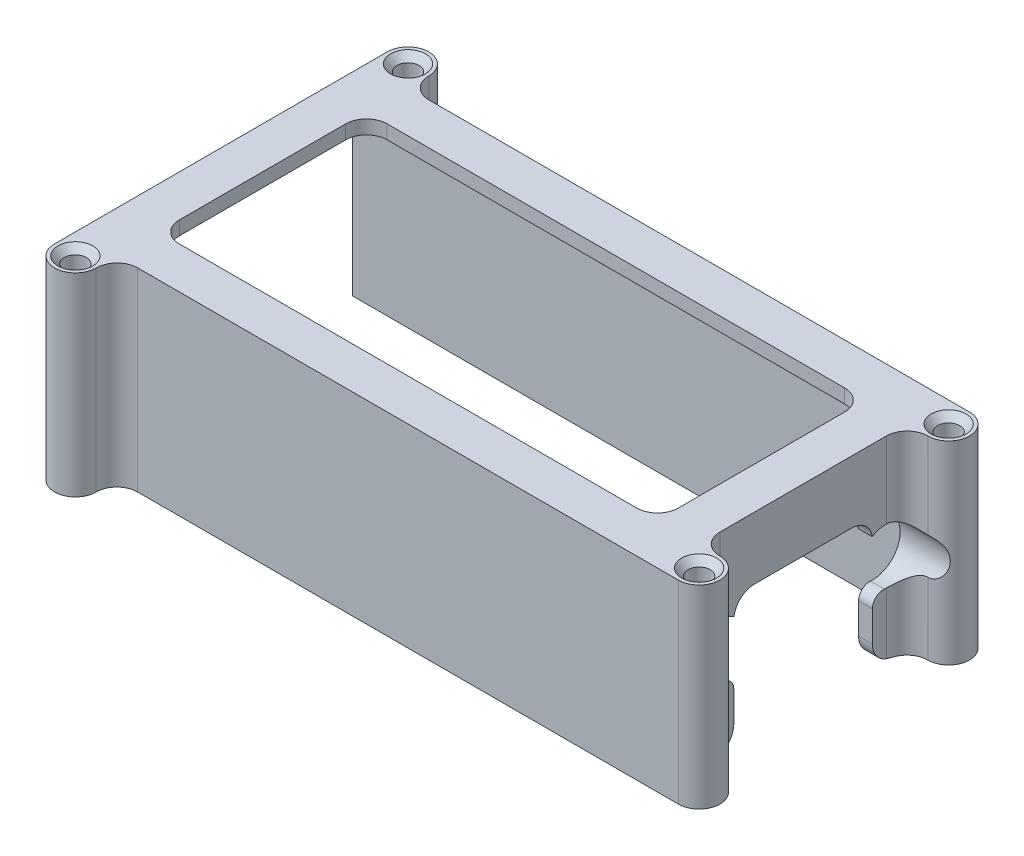
from build123d import *

# Parameters (mm, degrees)
SKETCH1_W           = 133.35
SKETCH1_H           = 66.675
SKETCH1_W_2         = 127
SKETCH1_H_2         = 60.325
BOSS_EXTRUDE1_DEPTH = 41.275
SKETCH2_W           = 31.75
SKETCH2_H           = 60.325
CUT_EXTRUDE1_DEPTH  = 134.35
SKETCH3_W           = 133.35
SKETCH3_H           = 66.675
SKETCH3_W_2         = 114.3
SKETCH3_H_2         = 47.625
BOSS_EXTRUDE2_DEPTH = 3.175
BOSS_EXTRUDE3_DEPTH = 44.45
SKETCH6_R           = 2.54
BOSS_EXTRUDE4_DEPTH = 44.45
CUT_EXTRUDE2_DEPTH  = 4.175
FILLET1_R           = 1.5875
FILLET2_R           = 4.7625
SKETCH9_R           = 6.35
CUT_EXTRUDE4_DEPTH  = 13.7
FILLET3_R           = 2.54


with BuildPart() as part:
    # Sketch1 → Boss-Extrude1 (new body)
    with BuildSketch(Plane(origin=(0, 0, 0), x_dir=(1, 0, 0), z_dir=(0, 1, 0))):
        Rectangle(SKETCH1_W, SKETCH1_H)
        Rectangle(SKETCH1_W_2, SKETCH1_H_2, mode=Mode.SUBTRACT)
    extrude(amount=BOSS_EXTRUDE1_DEPTH)

    # Sketch2 → Cut-Extrude1 (cut, through all)
    with BuildSketch(Plane.ZY.offset(66.675)):
        Rectangle(SKETCH2_W, SKETCH2_H)
    extrude(amount=-CUT_EXTRUDE1_DEPTH, mode=Mode.SUBTRACT)

    # Sketch3 → Boss-Extrude2 (add)
    with BuildSketch(Plane(origin=(0, 41.275, 0), x_dir=(1, 0, 0), z_dir=(0, 1, 0))):
        Rectangle(SKETCH3_W, SKETCH3_H)
        Rectangle(SKETCH3_W_2, SKETCH3_H_2, mode=Mode.SUBTRACT)
    extrude(amount=BOSS_EXTRUDE2_DEPTH)

    # Sketch4 → Boss-Extrude3 (add)
    with BuildSketch(Plane(origin=(0, 44.45, 0), x_dir=(1, 0, 0), z_dir=(0, 1, 0))):
        with BuildLine():
            Line((71.4375, 33.3375), (66.675, 33.3375))
            Line((66.675, 33.3375), (66.675, 19.05))
            ThreePointArc((66.675, 19.05), (68.069903955, 22.417596045), (71.4375, 23.8125))
            ThreePointArc((71.4375, 23.8125), (76.2, 28.575), (71.4375, 33.3375))
        make_face()
    boss_extrude3 = extrude(amount=-BOSS_EXTRUDE3_DEPTH)

    # Sketch5 → Cut-Revolve1 (revolve, cut)
    with BuildSketch(Plane.YZ.offset(71.4375)):
        Polygon((0, -31.115), (42.8625, -31.115), (44.45, -32.569675739), (44.45, -28.575), (0, -28.575), align=None)
    cut_revolve1 = revolve(axis=Axis((71.4375, 44.45, -28.575), (0, -1, 0)), mode=Mode.SUBTRACT)

    # Sketch6 → Boss-Extrude4 (add)
    with BuildSketch(Plane(origin=(0, 44.45, 0), x_dir=(1, 0, 0), z_dir=(0, 1, 0))):
        with BuildLine():
            Line((-66.675, 38.1), (-66.675, 33.3375))
            Line((-66.675, 33.3375), (-52.3875, 33.3375))
            ThreePointArc((-52.3875, 33.3375), (-55.755096045, 34.732403955), (-57.15, 38.1))
            ThreePointArc((-57.15, 38.1), (-61.9125, 42.8625), (-66.675, 38.1))
        make_face()
        with Locations((-61.9125, 38.1)):
            Circle(SKETCH6_R, mode=Mode.SUBTRACT)
    boss_extrude4 = extrude(amount=-BOSS_EXTRUDE4_DEPTH)

    # Sketch7 → Cut-Revolve2 (revolve, cut)
    with BuildSketch(Plane(origin=(-61.9125, 0, 0), x_dir=(0, 1, 0), z_dir=(-1, 0, 0))):
        Polygon((42.8625, 40.64), (44.45, 42.094675739), (44.45, 38.1), (42.8625, 38.1), align=None)
    cut_revolve2 = revolve(axis=Axis((-61.9125, 42.8625, -38.1), (0, -1, 0)), mode=Mode.SUBTRACT)

    # Mirror1: Boss-Extrude3, Cut-Revolve1, Boss-Extrude4, Cut-Revolve2 across plane
    add(boss_extrude3.mirror(Plane.XY))
    add(cut_revolve1.mirror(Plane.XY), mode=Mode.SUBTRACT)
    add(boss_extrude4.mirror(Plane.XY))
    add(cut_revolve2.mirror(Plane.XY), mode=Mode.SUBTRACT)

    # Sketch8 → Cut-Extrude2 (cut, through all)
    with BuildSketch(Plane(origin=(-63.5, 0, 0), x_dir=(0, 0, -1), z_dir=(1, 0, 0))):
        Polygon((-15.875, 0), (-15.875, 30.1625), (15.875, 30.1625), (15.875, 0), (30.1625, 0), (30.1625, 41.275), (-30.1625, 41.275), (-30.1625, 0), align=None)
    extrude(amount=-CUT_EXTRUDE2_DEPTH, mode=Mode.SUBTRACT)

    # Fillet1
    fillet1_edges = [part.edges().sort_by_distance(p)[0] for p in [
        (63.5, 20.6375, 30.1625),
        (63.5, 20.6375, -30.1625),
        (63.5, 41.275, 0),
        (-1.5875, 41.275, -30.1625),
        (-1.5875, 41.275, 30.1625),
    ]]
    fillet(fillet1_edges, radius=FILLET1_R)

    # Fillet2
    fillet2_edges = [part.edges().sort_by_distance(p)[0] for p in [
        (65.0875, 0, 15.875),
        (65.0875, 30.1625, 15.875),
        (65.0875, 0, -15.875),
        (65.0875, 30.1625, -15.875),
        (-57.15, 42.8625, 23.8125),
        (57.15, 42.8625, 23.8125),
        (57.15, 42.8625, -23.8125),
        (-57.15, 42.8625, -23.8125),
    ]]
    fillet(fillet2_edges, radius=FILLET2_R)

    # Sketch9 → Cut-Extrude4 (cut, through all)
    with BuildSketch(Plane.ZY.offset(-63.5)):
        with Locations((19.05, 20.6375)):
            Circle(SKETCH9_R)
        with Locations((-19.05, 20.6375)):
            Circle(SKETCH9_R)
    extrude(amount=-CUT_EXTRUDE4_DEPTH, mode=Mode.SUBTRACT)

    # Fillet3
    fillet3_edges = [part.edges().sort_by_distance(p)[0] for p in [
        (65.0875, 15.138238686, 15.875),
        (65.0875, 15.138238686, -15.875),
    ]]
    fillet(fillet3_edges, radius=FILLET3_R)


solid = part.part
